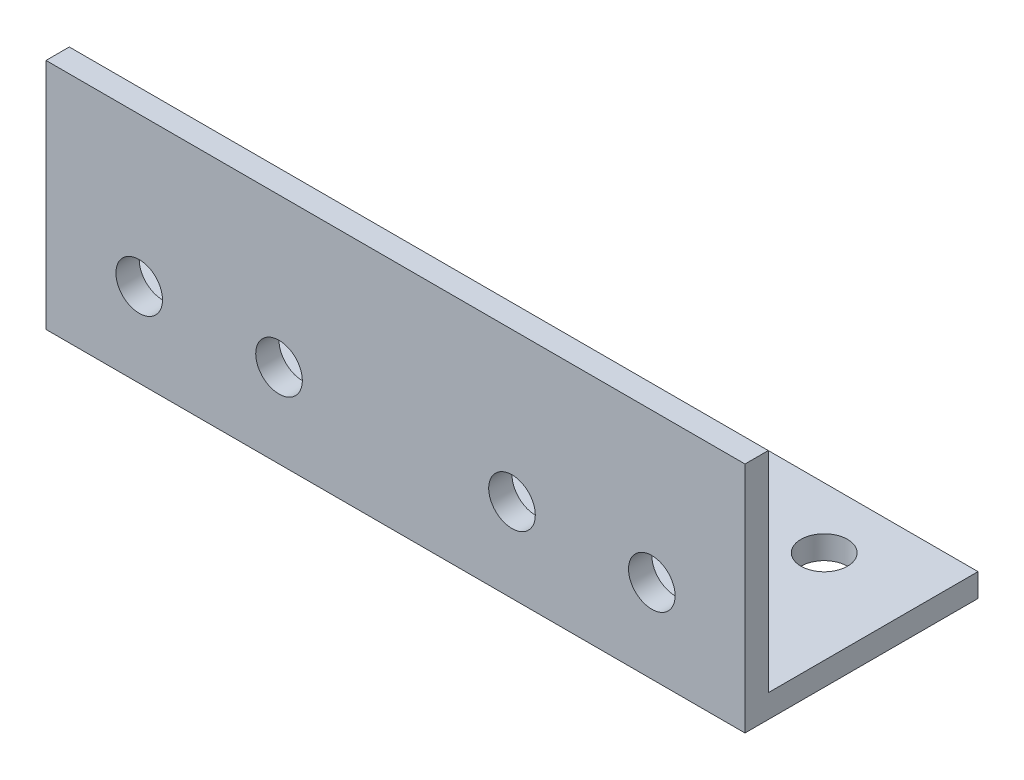
from build123d import *

# Parameters (mm, degrees)
EXTRUDE_1_DEPTH     = 150
SKETCH_2_R          = 5
CUT_EXTRUDE_1_DEPTH = 51
SKETCH_3_R          = 5
CUT_EXTRUDE_3_DEPTH = 51


with BuildPart() as part:
    # Эскиз1 → Вытянуть-Тонкостенный1 (new body)
    with BuildSketch(Plane(origin=(0, 0, 0), x_dir=(0, 0, -1), z_dir=(1, 0, 0))):
        Polygon((50, 0), (0, 0), (0, 50), (5, 50), (5, 5), (50, 5), align=None)
    extrude(amount=EXTRUDE_1_DEPTH)

    # Эскиз2 → Вырез-Вытянуть1 (cut, through all)
    with BuildSketch(Plane.XZ):
        with Locations((130, -37)):
            Circle(SKETCH_2_R)
        with Locations((100, -37)):
            Circle(SKETCH_2_R)
        with Locations((50, -37)):
            Circle(SKETCH_2_R)
        with Locations((20, -37)):
            Circle(SKETCH_2_R)
    extrude(amount=-CUT_EXTRUDE_1_DEPTH, mode=Mode.SUBTRACT)

    # Эскиз3 → Вырез-Вытянуть3 (cut, through all)
    with BuildSketch(Plane.XY):
        with Locations((130, 18)):
            Circle(SKETCH_3_R)
        with Locations((100, 18)):
            Circle(SKETCH_3_R)
        with Locations((50, 18)):
            Circle(SKETCH_3_R)
        with Locations((20, 18)):
            Circle(SKETCH_3_R)
    extrude(amount=-CUT_EXTRUDE_3_DEPTH, mode=Mode.SUBTRACT)


solid = part.part
